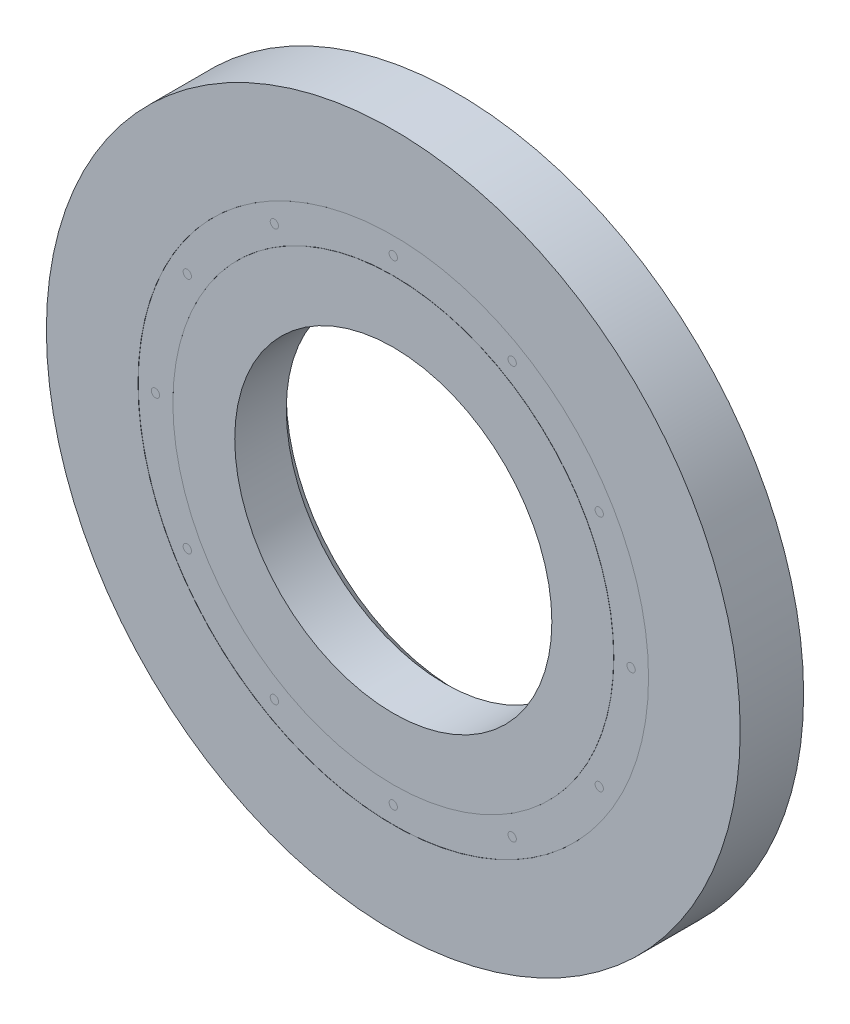
from build123d import *

# Parameters (mm, degrees)
CIRPATTERN1_COUNT  = 12
SKETCH5_W          = 1.147826059
SKETCH5_H          = 0.697802198
SKETCH6_W          = 1.27
SKETCH6_H          = 1.835498901
SKETCH7_R          = 6.35
CUT_EXTRUDE1_DEPTH = 21.692531665


with BuildPart() as part:
    # Sketch1 → Revolve1 (revolve)
    with BuildSketch(Plane(origin=(0, 0, 0), x_dir=(0, 0, -1), z_dir=(1, 0, 0))):
        with BuildLine():
            Line((2.143125, 6.35), (-2.143125, 6.35))
            Line((-2.143125, 6.35), (-2.38125, 6.111875))
            Line((-2.38125, 6.111875), (-2.38125, 5.111401099))
            Line((-2.38125, 5.111401099), (-1.058333333, 5.111401099))
            ThreePointArc((-1.058333333, 5.111401099), (0, 5.876861441), (1.058333333, 5.111401099))
            Line((1.058333333, 5.111401099), (2.38125, 5.111401099))
            Line((2.38125, 5.111401099), (2.38125, 6.111875))
            Line((2.38125, 6.111875), (2.143125, 6.35))
        make_face()
    revolve(axis=Axis((0, 0, 2.38125), (0, 0, -1)))

    # Sketch6 → Revolve6 (revolve)
    with BuildSketch(Plane(origin=(0, 0, 0), x_dir=(0, 0, -1), z_dir=(1, 0, 0))):
        with Locations((1.74625, 6.02915055)):
            Rectangle(SKETCH6_W, SKETCH6_H)
    revolve(axis=Axis((0, 0, -2.38125), (0, 0, 1)))


with BuildPart() as body_2:
    # Sketch3 → Revolve3 (revolve)
    with BuildSketch(Plane(origin=(0, 0, 0), x_dir=(0, 0, -1), z_dir=(1, 0, 0))):
        with BuildLine():
            Line((-2.38125, 4.413598901), (-1.058333333, 4.413598901))
            ThreePointArc((-1.058333333, 4.413598901), (0, 3.648138559), (1.058333333, 4.413598901))
            Line((1.058333333, 4.413598901), (2.38125, 4.413598901))
            Line((2.38125, 4.413598901), (2.38125, 3.413125))
            Line((2.38125, 3.413125), (2.143125, 3.175))
            Line((2.143125, 3.175), (-2.143125, 3.175))
            Line((-2.143125, 3.175), (-2.38125, 3.413125))
            Line((-2.38125, 3.413125), (-2.38125, 4.413598901))
        make_face()
    revolve(axis=Axis((0, 0, 2.38125), (0, 0, -1)))


with BuildPart() as body_3:
    # Sketch4 → Revolve4 (revolve)
    with BuildSketch(Plane(origin=(0, 0, 0), x_dir=(0, 0, -1), z_dir=(1, 0, 0))):
        with BuildLine():
            Line((-1.114361441, 4.7625), (1.114361441, 4.7625))
            ThreePointArc((1.114361441, 4.7625), (0, 5.876861441), (-1.114361441, 4.7625))
        make_face()
    revolve(axis=Axis((0, 4.7625, 1.114361441), (0, 0, -1)))


with BuildPart() as cirpattern1_1:
    # CirPattern1: pattern copy
    add(body_3.part.rotate(Axis((0, 0, -2.38125), (0, 0, 1)), 1 * 360 / CIRPATTERN1_COUNT))


with BuildPart() as cirpattern1_2:
    # CirPattern1: pattern copy
    add(body_3.part.rotate(Axis((0, 0, -2.38125), (0, 0, 1)), 2 * 360 / CIRPATTERN1_COUNT))


with BuildPart() as cirpattern1_3:
    # CirPattern1: pattern copy
    add(body_3.part.rotate(Axis((0, 0, -2.38125), (0, 0, 1)), 3 * 360 / CIRPATTERN1_COUNT))


with BuildPart() as cirpattern1_4:
    # CirPattern1: pattern copy
    add(body_3.part.rotate(Axis((0, 0, -2.38125), (0, 0, 1)), 4 * 360 / CIRPATTERN1_COUNT))


with BuildPart() as cirpattern1_5:
    # CirPattern1: pattern copy
    add(body_3.part.rotate(Axis((0, 0, -2.38125), (0, 0, 1)), 5 * 360 / CIRPATTERN1_COUNT))


with BuildPart() as cirpattern1_6:
    # CirPattern1: pattern copy
    add(body_3.part.rotate(Axis((0, 0, -2.38125), (0, 0, 1)), 6 * 360 / CIRPATTERN1_COUNT))


with BuildPart() as cirpattern1_7:
    # CirPattern1: pattern copy
    add(body_3.part.rotate(Axis((0, 0, -2.38125), (0, 0, 1)), 7 * 360 / CIRPATTERN1_COUNT))


with BuildPart() as cirpattern1_8:
    # CirPattern1: pattern copy
    add(body_3.part.rotate(Axis((0, 0, -2.38125), (0, 0, 1)), 8 * 360 / CIRPATTERN1_COUNT))


with BuildPart() as cirpattern1_9:
    # CirPattern1: pattern copy
    add(body_3.part.rotate(Axis((0, 0, -2.38125), (0, 0, 1)), 9 * 360 / CIRPATTERN1_COUNT))


with BuildPart() as cirpattern1_10:
    # CirPattern1: pattern copy
    add(body_3.part.rotate(Axis((0, 0, -2.38125), (0, 0, 1)), 10 * 360 / CIRPATTERN1_COUNT))


with BuildPart() as cirpattern1_11:
    # CirPattern1: pattern copy
    add(body_3.part.rotate(Axis((0, 0, -2.38125), (0, 0, 1)), 11 * 360 / CIRPATTERN1_COUNT))


with BuildPart() as body_15:
    # Sketch5 → Revolve5 (revolve)
    with BuildSketch(Plane(origin=(0, 0, 0), x_dir=(0, 0, -1), z_dir=(1, 0, 0))):
        with Locations((-1.688274471, 4.7625)):
            Rectangle(SKETCH5_W, SKETCH5_H)
        with Locations((1.688274471, 4.7625)):
            Rectangle(SKETCH5_W, SKETCH5_H)
    revolve(axis=Axis((0, 0, 2.38125), (0, 0, -1)))


with BuildPart() as cut_extrude1_tool:
    # Sketch7 → Cut-Extrude1 (new, through all)
    with BuildSketch(Plane(origin=(-4.885869902, 9.665410703, -1.11125), x_dir=(-0.7071067811865512, 0.7071067811865439, 0), z_dir=(0, 0, -1))):
        with Locations((-10.289309191, -3.379645711)):
            Circle(SKETCH7_R)
    extrude(amount=-CUT_EXTRUDE1_DEPTH)


with BuildPart() as part_1:
    add(part.part)

    # Cut-Extrude1: cut by cut_extrude1_tool
    add(cut_extrude1_tool.part, mode=Mode.SUBTRACT)


with BuildPart() as body_2_1:
    add(body_2.part)

    # Cut-Extrude1: cut by cut_extrude1_tool
    add(cut_extrude1_tool.part, mode=Mode.SUBTRACT)


with BuildPart() as body_3_1:
    add(body_3.part)

    # Cut-Extrude1: cut by cut_extrude1_tool
    add(cut_extrude1_tool.part, mode=Mode.SUBTRACT)


with BuildPart() as cirpattern1_1_1:
    add(cirpattern1_1.part)

    # Cut-Extrude1: cut by cut_extrude1_tool
    add(cut_extrude1_tool.part, mode=Mode.SUBTRACT)


with BuildPart() as cirpattern1_2_1:
    add(cirpattern1_2.part)

    # Cut-Extrude1: cut by cut_extrude1_tool
    add(cut_extrude1_tool.part, mode=Mode.SUBTRACT)


with BuildPart() as cirpattern1_3_1:
    add(cirpattern1_3.part)

    # Cut-Extrude1: cut by cut_extrude1_tool
    add(cut_extrude1_tool.part, mode=Mode.SUBTRACT)


with BuildPart() as cirpattern1_4_1:
    add(cirpattern1_4.part)

    # Cut-Extrude1: cut by cut_extrude1_tool
    add(cut_extrude1_tool.part, mode=Mode.SUBTRACT)


with BuildPart() as cirpattern1_5_1:
    add(cirpattern1_5.part)

    # Cut-Extrude1: cut by cut_extrude1_tool
    add(cut_extrude1_tool.part, mode=Mode.SUBTRACT)


with BuildPart() as cirpattern1_6_1:
    add(cirpattern1_6.part)

    # Cut-Extrude1: cut by cut_extrude1_tool
    add(cut_extrude1_tool.part, mode=Mode.SUBTRACT)


with BuildPart() as cirpattern1_7_1:
    add(cirpattern1_7.part)

    # Cut-Extrude1: cut by cut_extrude1_tool
    add(cut_extrude1_tool.part, mode=Mode.SUBTRACT)


with BuildPart() as cirpattern1_8_1:
    add(cirpattern1_8.part)

    # Cut-Extrude1: cut by cut_extrude1_tool
    add(cut_extrude1_tool.part, mode=Mode.SUBTRACT)


with BuildPart() as cirpattern1_9_1:
    add(cirpattern1_9.part)

    # Cut-Extrude1: cut by cut_extrude1_tool
    add(cut_extrude1_tool.part, mode=Mode.SUBTRACT)


with BuildPart() as cirpattern1_10_1:
    add(cirpattern1_10.part)

    # Cut-Extrude1: cut by cut_extrude1_tool
    add(cut_extrude1_tool.part, mode=Mode.SUBTRACT)


with BuildPart() as cirpattern1_11_1:
    add(cirpattern1_11.part)

    # Cut-Extrude1: cut by cut_extrude1_tool
    add(cut_extrude1_tool.part, mode=Mode.SUBTRACT)


with BuildPart() as body_15_1:
    add(body_15.part)

    # Cut-Extrude1: cut by cut_extrude1_tool
    add(cut_extrude1_tool.part, mode=Mode.SUBTRACT)


solid = Compound([part_1.part, body_2_1.part, body_3_1.part, cirpattern1_1_1.part, cirpattern1_2_1.part, cirpattern1_3_1.part, cirpattern1_4_1.part, cirpattern1_5_1.part, cirpattern1_6_1.part, cirpattern1_7_1.part, cirpattern1_8_1.part, cirpattern1_9_1.part, cirpattern1_10_1.part, cirpattern1_11_1.part, body_15_1.part])
